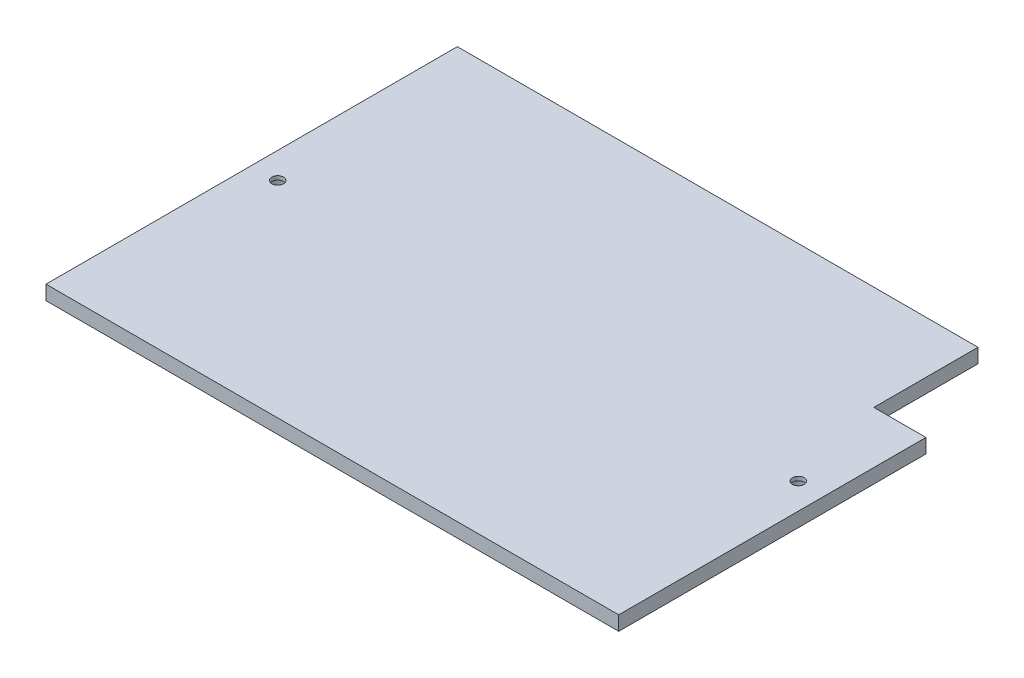
from build123d import *

# Parameters (mm, degrees)
SKETCH1_W                      = 220
SKETCH1_H                      = 158
BOSS_EXTRUDE1_DEPTH            = 5.5
CBORE_FOR_M4_SHCS1_D           = 4.5
CBORE_FOR_M4_SHCS1_CBORE_D     = 8
CBORE_FOR_M4_SHCS1_CBORE_DEPTH = 4
SKETCH6_W                      = 20
SKETCH6_H                      = 40
CUT_EXTRUDE2_DEPTH             = 6.5


with BuildPart() as part:
    # Sketch1 → Boss-Extrude1 (new body)
    with BuildSketch(Plane(origin=(0, 0, 0), x_dir=(1, 0, 0), z_dir=(0, 1, 0))):
        Rectangle(SKETCH1_W, SKETCH1_H)
    extrude(amount=BOSS_EXTRUDE1_DEPTH)

    # CBORE for M4 SHCS1 (through all)
    with Locations(Plane.XZ):
        with Locations((100, 0)):
            cbore_for_m4_shcs1 = CounterBoreHole(CBORE_FOR_M4_SHCS1_D / 2, CBORE_FOR_M4_SHCS1_CBORE_D / 2, CBORE_FOR_M4_SHCS1_CBORE_DEPTH)

    # Mirror2: CBORE for M4 SHCS1 across plane
    add(cbore_for_m4_shcs1.mirror(Plane(origin=(0, 0, 0), x_dir=(0, 0, 1), z_dir=(1, 0, 0))), mode=Mode.SUBTRACT)

    # Sketch6 → Cut-Extrude2 (cut, through all)
    with BuildSketch(Plane(origin=(0, 5.5, 0), x_dir=(1, 0, 0), z_dir=(0, 1, 0))):
        with Locations((100, 59)):
            Rectangle(SKETCH6_W, SKETCH6_H)
    extrude(amount=-CUT_EXTRUDE2_DEPTH, mode=Mode.SUBTRACT)


solid = part.part
